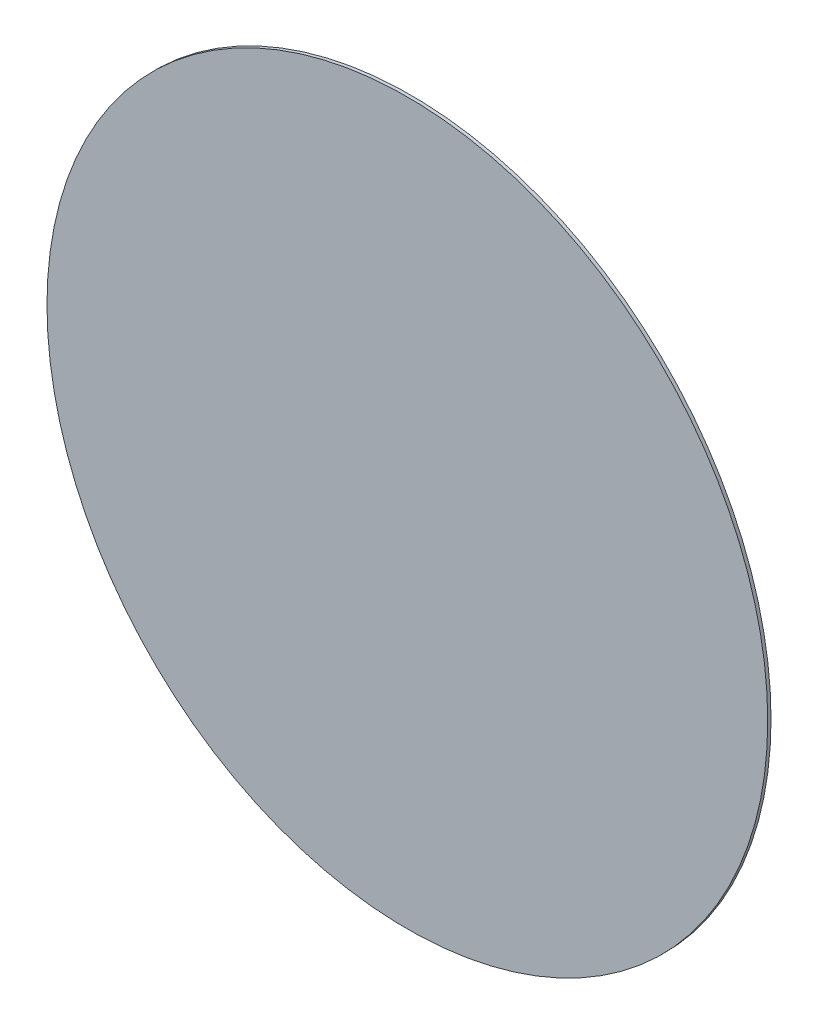
from build123d import *

# Parameters (mm, degrees)
SKETCH_1_R      = 11
EXTRUDE_1_DEPTH = 0.1


with BuildPart() as part:
    # 草图1 → 凸台-拉伸1 (new body)
    with BuildSketch(Plane.XY):
        Circle(SKETCH_1_R)
    extrude(amount=EXTRUDE_1_DEPTH)


solid = part.part
